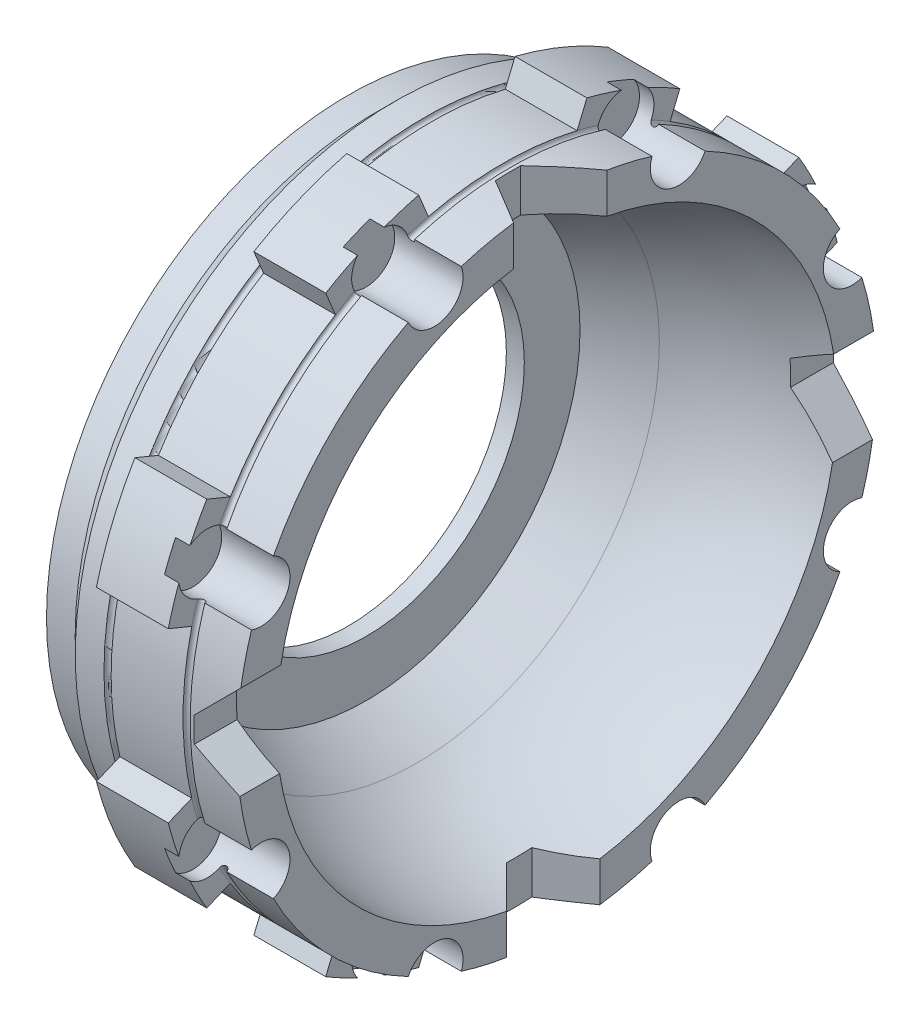
from build123d import *

# Parameters (mm, degrees)
P_IDAT_VYSUNUT_M1_DEPTH  = 10
SKICA4_R                 = 4
ODEBRAT_VYSUNUT_M1_DEPTH = 9.5
KRUHOV_POLE1_COUNT       = 8
ODEBRAT_VYSUNUT_M2_DEPTH = 9.5
KRUHOV_POLE2_COUNT       = 4


with BuildPart() as part:
    # Skica1 → Rotovat1 (revolve)
    with BuildSketch(Plane.XY):
        with BuildLine():
            Line((0, 42), (4, 42))
            Line((4, 42), (6.5, 44.5))
            Line((6.5, 44.5), (29, 44.5))
            Line((29, 44.5), (29, 39.016461137))
            ThreePointArc((29, 39.016461137), (18.906057241, 37.687568362), (9.5, 33.791451884))
            Line((9.5, 33.791451884), (2.5, 29.75))
            Line((2.5, 29.75), (2.5, 22))
            Line((2.5, 22), (0, 22))
            Line((0, 22), (0, 42))
        make_face()
    revolve(axis=Axis((0, 0, 0), (-1, 0, 0)))

    # Skica2 → Odebrat rotací1 (revolve, cut)
    with BuildSketch(Plane.XY):
        with BuildLine():
            Line((10.5, 44.5), (11.5, 44.5))
            ThreePointArc((11.5, 44.5), (11, 44), (10.5, 44.5))
        make_face()
        with BuildLine():
            Line((21.5, 44.5), (22.5, 44.5))
            ThreePointArc((22.5, 44.5), (22, 44), (21.5, 44.5))
        make_face()
    revolve(axis=Axis((0, 0, 0), (1, 0, 0)), mode=Mode.SUBTRACT)

    # Skica3 → Přidat vysunutím1 (add)
    with BuildSketch(Plane(origin=(21.5, 0, 0), x_dir=(0, 0, -1), z_dir=(1, 0, 0))):
        with BuildLine():
            Line((11.705270304, 46.550903827), (10.350245403, 43.279584334))
            ThreePointArc((10.350245403, 43.279584334), (17.02941274, 41.112639197), (23.284558858, 37.922016281))
            Line((23.284558858, 37.922016281), (24.639583759, 41.193335774))
            ThreePointArc((24.639583759, 41.193335774), (18.368804754, 44.346217561), (11.705270304, 46.550903827))
        make_face()
    p_idat_vysunut_m1 = extrude(amount=-P_IDAT_VYSUNUT_M1_DEPTH)

    # Skica4 → Odebrat vysunutím1 (cut)
    with BuildSketch(Plane(origin=(29, 0, 0), x_dir=(0, 0, -1), z_dir=(1, 0, 0))):
        with Locations((17.02941274, 41.112639197)):
            Circle(SKICA4_R)
    odebrat_vysunut_m1 = extrude(amount=-ODEBRAT_VYSUNUT_M1_DEPTH, mode=Mode.SUBTRACT)

    # Kruhové pole1: Přidat vysunutím1, Odebrat vysunutím1 ×8 about axis
    kruhov_pole1_axis = Axis((0, 0, 0), (1, 0, 0))
    for i in range(1, KRUHOV_POLE1_COUNT):
        add(p_idat_vysunut_m1.rotate(kruhov_pole1_axis, i * 360 / KRUHOV_POLE1_COUNT))
        add(odebrat_vysunut_m1.rotate(kruhov_pole1_axis, i * 360 / KRUHOV_POLE1_COUNT), mode=Mode.SUBTRACT)

    # Skica5 → Odebrat vysunutím2 (cut)
    with BuildSketch(Plane.XY.offset(44.5)):
        Polygon((29, 7), (29, -6), (23, -2.535898385), (23, 1), align=None)
    odebrat_vysunut_m2 = extrude(amount=-ODEBRAT_VYSUNUT_M2_DEPTH, mode=Mode.SUBTRACT)

    # Kruhové pole2: Odebrat vysunutím2 ×4 about axis
    kruhov_pole2_axis = Axis((0, 0, 0), (1, 0, 0))
    for i in range(1, KRUHOV_POLE2_COUNT):
        add(odebrat_vysunut_m2.rotate(kruhov_pole2_axis, i * 360 / KRUHOV_POLE2_COUNT), mode=Mode.SUBTRACT)


solid = part.part
